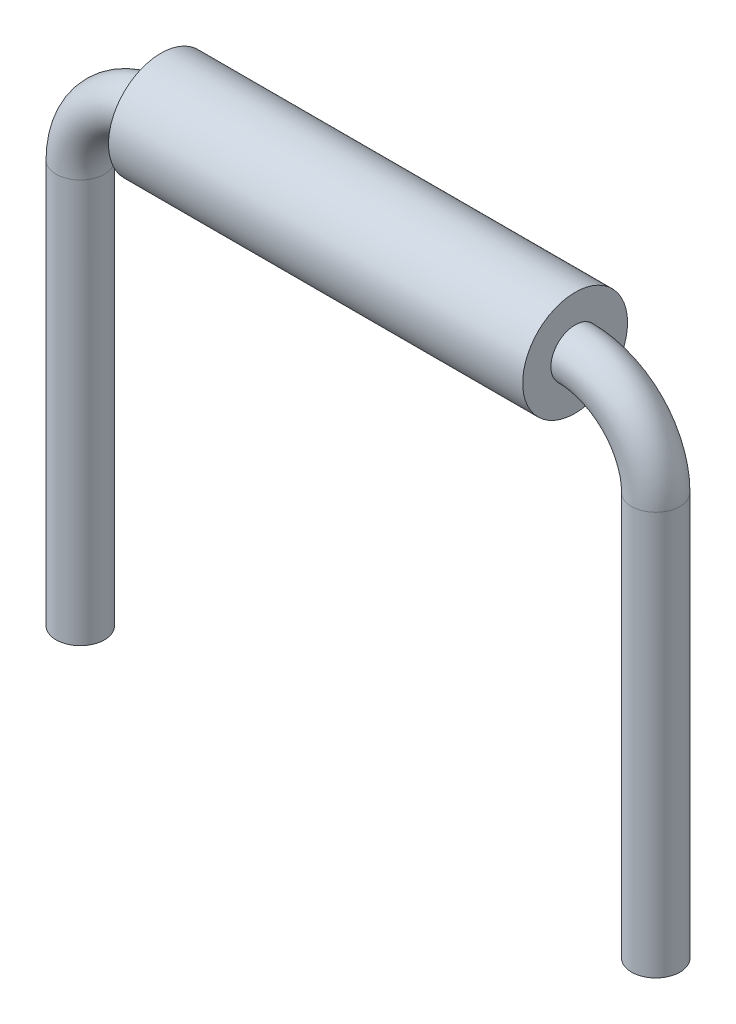
from build123d import *

# Parameters (mm, degrees)
SKETCH2_R                = 0.3
SKETCH3_R                = 0.65
SKETCH3_R_2              = 0.3
BOSS_EXTRUDE1_DEPTH      = 2.5675
BOSS_EXTRUDE1_DEPTH_BACK = 2.5675


with BuildPart() as part:
    # Sweep1: sweep along a path in Sketch1
    with BuildLine(Plane.XY) as sweep1_path:
        Line((-3.5675, -6), (-3.5675, -1))
        ThreePointArc((-3.5675, -1), (-3.274606781, -0.292893219), (-2.5675, 0))
        Line((-2.5675, 0), (2.5675, 0))
        ThreePointArc((2.5675, 0), (3.274606781, -0.292893219), (3.5675, -1))
        Line((3.5675, -1), (3.5675, -6))
    # Sketch2 → Sweep1 (sweep)
    with BuildSketch(Plane(origin=(0, 0, 0), x_dir=(0, 0, -1), z_dir=(1, 0, 0))):
        Circle(SKETCH2_R)
    sweep(path=sweep1_path.line)


with BuildPart() as body_2:
    # Sketch3 → Boss-Extrude1 (new body, two sides)
    with BuildSketch(Plane(origin=(0, 0, 0), x_dir=(0, 0, -1), z_dir=(1, 0, 0))) as boss_extrude1_sk:
        Circle(SKETCH3_R)
        Circle(SKETCH3_R_2, mode=Mode.SUBTRACT)
    extrude(amount=BOSS_EXTRUDE1_DEPTH)
    extrude(boss_extrude1_sk.sketch, amount=-BOSS_EXTRUDE1_DEPTH_BACK)


solid = Compound([part.part, body_2.part])
